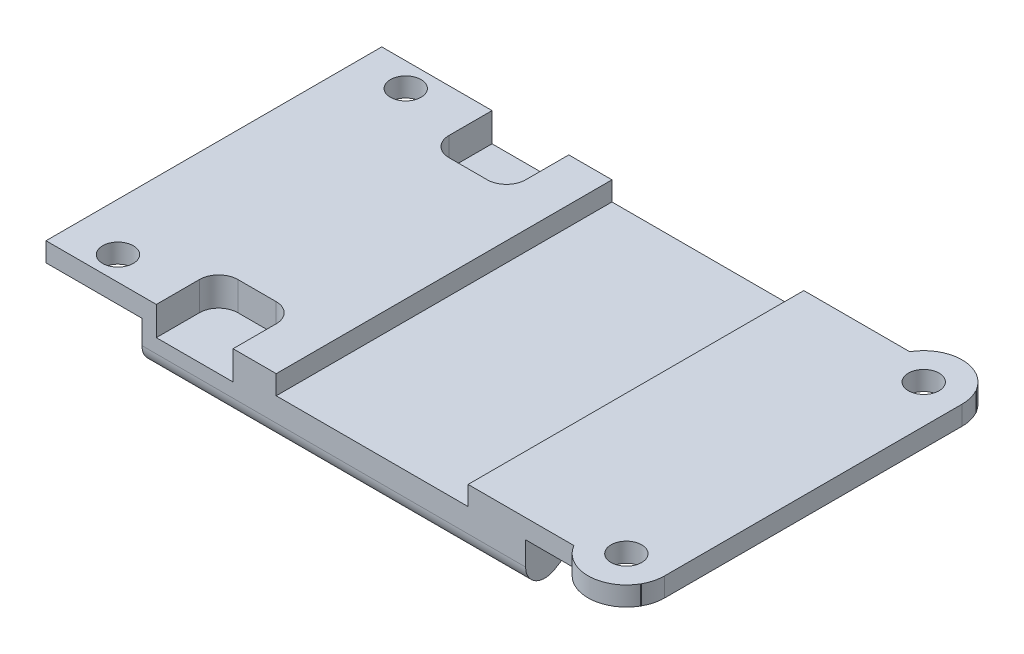
from build123d import *

# Parameters (mm, degrees)
SKETCH1_W               = 40
SKETCH1_H               = 35
BOSS_EXTRUDE1_DEPTH     = 8
CUT_EXTRUDE1_DEPTH      = 45.38749824
CUT_EXTRUDE1_DEPTH_BACK = 45.38749824
FILLET1_R               = 2
SKETCH4_W               = 35
SKETCH4_H               = 2
BOSS_EXTRUDE2_DEPTH     = 10
SKETCH5_W               = 35
SKETCH5_H               = 2
BOSS_EXTRUDE3_DEPTH     = 12
SKETCH6_R               = 1.6
CUT_EXTRUDE2_DEPTH      = 10
SKETCH7_W               = 8
SKETCH7_H               = 6.5
CUT_EXTRUDE3_DEPTH      = 3
SKETCH8_W               = 20
SKETCH8_H               = 2
CUT_EXTRUDE5_DEPTH      = 48.862616922
FILLET2_R               = 2
SKETCH10_R              = 1.6
CUT_EXTRUDE6_DEPTH      = 37.745198621
BOSS_EXTRUDE4_DEPTH     = 2


with BuildPart() as part:
    # Sketch1 → Boss-Extrude1 (new body)
    with BuildSketch(Plane(origin=(0, 0, 0), x_dir=(1, 0, 0), z_dir=(0, 1, 0))):
        Rectangle(SKETCH1_W, SKETCH1_H)
    extrude(amount=-BOSS_EXTRUDE1_DEPTH)

    # Sketch2 → Cut-Extrude1 (cut, two sides: drawn at the far end of the back side and taken through both)
    with BuildSketch(Plane(origin=(20, 0, 0), x_dir=(0, 0, -1), z_dir=(1, 0, 0)).offset(-CUT_EXTRUDE1_DEPTH_BACK)):
        Polygon((-12.5, -5), (-17.5, -8), (17.5, -8), (12.5, -5), align=None)
    extrude(amount=CUT_EXTRUDE1_DEPTH + CUT_EXTRUDE1_DEPTH_BACK, mode=Mode.SUBTRACT)

    # Fillet1
    fillet1_edges = [part.edges().sort_by_distance(p)[0] for p in [
        (0, -5, 12.5),
        (0, -5, -12.5),
        (0, -8, -17.5),
        (0, -8, 17.5),
    ]]
    fillet(fillet1_edges, radius=FILLET1_R)

    # Sketch4 → Boss-Extrude2 (add)
    with BuildSketch(Plane.ZY.offset(20)):
        with Locations((0, -1)):
            Rectangle(SKETCH4_W, SKETCH4_H)
    extrude(amount=BOSS_EXTRUDE2_DEPTH)

    # Sketch5 → Boss-Extrude3 (add)
    with BuildSketch(Plane(origin=(20, 0, 0), x_dir=(0, 0, -1), z_dir=(1, 0, 0))):
        with Locations((0, -1)):
            Rectangle(SKETCH5_W, SKETCH5_H)
    extrude(amount=BOSS_EXTRUDE3_DEPTH)

    # Sketch6 → Cut-Extrude2 (cut)
    with BuildSketch(Plane.XZ.offset(2)):
        with Locations((-25, 15)):
            Circle(SKETCH6_R)
        with Locations((-25, -15)):
            Circle(SKETCH6_R)
    extrude(amount=-CUT_EXTRUDE2_DEPTH, mode=Mode.SUBTRACT)

    # Sketch7 → Cut-Extrude3 (cut)
    with BuildSketch(Plane(origin=(0, 0, 0), x_dir=(1, 0, 0), z_dir=(0, 1, 0))):
        Polygon((-18.5, -19), (-10.5, -19), (-10.5, -11), (-18.5, -11), (-18.5, -15), align=None)
        with Locations((-14.5, 14.25)):
            Rectangle(SKETCH7_W, SKETCH7_H)
    extrude(amount=-CUT_EXTRUDE3_DEPTH, mode=Mode.SUBTRACT)

    # Sketch8 → Cut-Extrude5 (cut, through all)
    with BuildSketch(Plane.XY.offset(17.5)):
        with Locations((4, -1)):
            Rectangle(SKETCH8_W, SKETCH8_H)
    extrude(amount=-CUT_EXTRUDE5_DEPTH, mode=Mode.SUBTRACT)

    # Fillet2
    fillet2_edges = [part.edges().sort_by_distance(p)[0] for p in [
        (-18.5, -1.5, 11),
        (-10.5, -1.5, 11),
        (-18.5, -1.5, -11),
        (-10.5, -1.5, -11),
    ]]
    fillet(fillet2_edges, radius=FILLET2_R)

    # Sketch10 → Cut-Extrude6 (cut, through all)
    with BuildSketch(Plane.XZ.offset(2)):
        with Locations((28.5, 15.5)):
            Circle(SKETCH10_R)
        with Locations((28.5, -15.5)):
            Circle(SKETCH10_R)
    extrude(amount=-CUT_EXTRUDE6_DEPTH, mode=Mode.SUBTRACT)

    # Sketch10_4 → Boss-Extrude4 (add)
    with BuildSketch(Plane.XZ.offset(2)):
        with BuildLine():
            Line((32.5, -15.5), (32.5, 15.5))
            ThreePointArc((32.5, 15.5), (32.372983346, 16.5), (32, 17.436491673))
            Line((32, 17.436491673), (32, -17.436491673))
            ThreePointArc((32, -17.436491673), (32.372983346, -16.5), (32.5, -15.5))
        make_face()
        with BuildLine():
            Line((31.964101615, -17.5), (25.035898385, -17.5))
            ThreePointArc((25.035898385, -17.5), (28.5, -19.5), (31.964101615, -17.5))
        make_face()
        with BuildLine():
            ThreePointArc((31.964101615, 17.5), (28.5, 19.5), (25.035898385, 17.5))
            Line((25.035898385, 17.5), (31.964101615, 17.5))
        make_face()
    extrude(amount=-BOSS_EXTRUDE4_DEPTH)


solid = part.part
